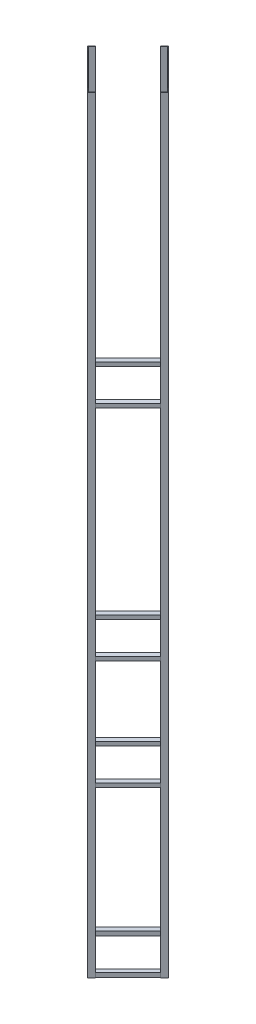
from build123d import *

# Parameters (mm, degrees)
BOSS_EXTRUDE6_DEPTH   = 1778
BOSS_EXTRUDE6_2_DEPTH = 1778
BOSS_EXTRUDE6_3_DEPTH = 1778
BOSS_EXTRUDE6_4_DEPTH = 1778
SKETCH11_W            = 11.1125
SKETCH11_H            = 9.525
BOSS_EXTRUDE11_DEPTH  = 129.12986
SKETCH13_W            = 11.1125
SKETCH13_H            = 9.525
BOSS_EXTRUDE13_DEPTH  = 118.01736
SKETCH14_W            = 11.1125
SKETCH14_H            = 9.525
BOSS_EXTRUDE14_DEPTH  = 119.60486
SKETCH15_W            = 11.1125
SKETCH15_H            = 9.525
BOSS_EXTRUDE15_DEPTH  = 106.90486
LPATTERN1_COUNT       = 2
LPATTERN1_PITCH       = 381
LPATTERN2_COUNT       = 2
LPATTERN2_PITCH       = 635
LPATTERN3_COUNT       = 2
LPATTERN3_PITCH       = 1143
SKETCH16_W            = 12.7
SKETCH16_H            = 12.7
BOSS_EXTRUDE16_DEPTH  = 0.0254
SKETCH17_W            = 12.7
SKETCH17_H            = 12.7
BOSS_EXTRUDE17_DEPTH  = 0.0254
SKETCH18_W            = 1.5875
SKETCH18_H            = 12.7
BOSS_EXTRUDE18_DEPTH  = 0.0254
SKETCH19_W            = 1.5875
SKETCH19_H            = 12.7
BOSS_EXTRUDE19_DEPTH  = 0.0254


with BuildPart() as part:
    # Sketch2 → Boss-Extrude6 (new body)
    with BuildSketch(Plane(origin=(0, 0, 0), x_dir=(1, 0, 0), z_dir=(0, 1, 0))):
        Polygon((0, 93.553663338), (-8.980256121, 84.573407217), (-7.857724106, 83.450875201), (0, 91.308599307), (7.857724106, 83.450875201), (8.980256121, 84.573407217), align=None)
    extrude(amount=BOSS_EXTRUDE6_DEPTH)



with BuildPart() as body_2:
    # Sketch2 → Boss-Extrude6 2 (new body)
    with BuildSketch(Plane(origin=(0, 0, 0), x_dir=(1, 0, 0), z_dir=(0, 1, 0))):
        Polygon((93.553663338, 0), (84.573407217, 8.980256121), (83.450875201, 7.857724106), (91.308599307, 0), (83.450875201, -7.857724106), (84.573407217, -8.980256121), align=None)
    extrude(amount=BOSS_EXTRUDE6_2_DEPTH)



with BuildPart() as body_3:
    # Sketch2 → Boss-Extrude6 3 (new body)
    with BuildSketch(Plane(origin=(0, 0, 0), x_dir=(1, 0, 0), z_dir=(0, 1, 0))):
        Polygon((0, -93.553663338), (8.980256121, -84.573407217), (7.857724106, -83.450875201), (0, -91.308599307), (-7.857724106, -83.450875201), (-8.980256121, -84.573407217), align=None)
    extrude(amount=BOSS_EXTRUDE6_3_DEPTH)



with BuildPart() as body_4:
    # Sketch2 → Boss-Extrude6 4 (new body)
    with BuildSketch(Plane(origin=(0, 0, 0), x_dir=(1, 0, 0), z_dir=(0, 1, 0))):
        Polygon((-93.553663338, 0), (-84.573407217, -8.980256121), (-83.450875201, -7.857724106), (-91.308599307, 0), (-83.450875201, 7.857724106), (-84.573407217, 8.980256121), align=None)
    extrude(amount=BOSS_EXTRUDE6_4_DEPTH)


with BuildPart() as body_3_1:
    add(body_3.part)

    add(body_4.part)  # Boss-Extrude11 merges body 4
    # Sketch11 → Boss-Extrude11 (add)
    with BuildSketch(Plane(origin=(-45.654299654, 0, -45.654299654), x_dir=(0.707106781, 0, -0.707106781), z_dir=(0.707106781, 0, 0.707106781))):
        with Locations((-59.008679751, 4.7625)):
            Rectangle(SKETCH11_W, SKETCH11_H)
    boss_extrude11 = extrude(amount=BOSS_EXTRUDE11_DEPTH)


with BuildPart() as body_2_1:
    add(body_2.part)

    add(body_3_1.part)  # Boss-Extrude13 merges body 3
    # Sketch13 → Boss-Extrude13 (add)
    with BuildSketch(Plane(origin=(-37.796575548, 0, 37.796575548), x_dir=(-0.707106781, 0, -0.707106781), z_dir=(0.707106781, 0, -0.707106781))):
        with Locations((-59.008679751, 4.7625)):
            Rectangle(SKETCH13_W, SKETCH13_H)
    boss_extrude13 = extrude(amount=BOSS_EXTRUDE13_DEPTH)


with BuildPart() as part_1:
    add(part.part)

    add(body_2_1.part)  # Boss-Extrude14 merges body 2
    # Sketch14 → Boss-Extrude14 (add)
    with BuildSketch(Plane(origin=(37.796575548, 0, 37.796575548), x_dir=(-0.707106781, 0, 0.707106781), z_dir=(-0.707106781, 0, -0.707106781))):
        with Locations((-59.008679751, 4.7625)):
            Rectangle(SKETCH14_W, SKETCH14_H)
    boss_extrude14 = extrude(amount=BOSS_EXTRUDE14_DEPTH)

    # Sketch15 → Boss-Extrude15 (add)
    with BuildSketch(Plane(origin=(37.796575548, 0, -37.796575548), x_dir=(0.707106781, 0, 0.707106781), z_dir=(-0.707106781, 0, 0.707106781))):
        with Locations((-59.008679751, 4.7625)):
            Rectangle(SKETCH15_W, SKETCH15_H)
    boss_extrude15 = extrude(amount=BOSS_EXTRUDE15_DEPTH)

    # LPattern1: Boss-Extrude11, Boss-Extrude13, Boss-Extrude14, Boss-Extrude15 ×2
    with Locations(*[(0, i * LPATTERN1_PITCH, 0) for i in range(1, LPATTERN1_COUNT)]):
        add(boss_extrude11)
        add(boss_extrude13)
        add(boss_extrude14)
        add(boss_extrude15)

    # LPattern2: Boss-Extrude11, Boss-Extrude13, Boss-Extrude14, Boss-Extrude15 ×2
    with Locations(*[(0, i * LPATTERN2_PITCH, 0) for i in range(1, LPATTERN2_COUNT)]):
        add(boss_extrude11)
        add(boss_extrude13)
        add(boss_extrude14)
        add(boss_extrude15)

    # LPattern3: Boss-Extrude11, Boss-Extrude13, Boss-Extrude14, Boss-Extrude15 ×2
    with Locations(*[(0, i * LPATTERN3_PITCH, 0) for i in range(1, LPATTERN3_COUNT)]):
        add(boss_extrude11)
        add(boss_extrude13)
        add(boss_extrude14)
        add(boss_extrude15)

    # Sketch16 → Boss-Extrude16 (add)
    with BuildSketch(Plane(origin=(-46.776831669, 0, 46.776831669), x_dir=(0.707106781, 0, 0.707106781), z_dir=(-0.707106781, 0, 0.707106781))):
        with Locations((-59.802429751, 1771.65)):
            Rectangle(SKETCH16_W, SKETCH16_H)
    extrude(amount=BOSS_EXTRUDE16_DEPTH)

    # Sketch17 → Boss-Extrude17 (add)
    with BuildSketch(Plane(origin=(-46.776831669, 0, 46.776831669), x_dir=(0.707106781, 0, 0.707106781), z_dir=(-0.707106781, 0, 0.707106781))):
        with Locations((59.802429751, 1771.65)):
            Rectangle(SKETCH17_W, SKETCH17_H)
    extrude(amount=BOSS_EXTRUDE17_DEPTH)

    # Sketch18 → Boss-Extrude18 (add)
    with BuildSketch(Plane(origin=(37.796575548, 0, -37.796575548), x_dir=(0.707106781, 0, 0.707106781), z_dir=(-0.707106781, 0, 0.707106781))):
        with Locations((-65.358679751, 1771.65)):
            Rectangle(SKETCH18_W, SKETCH18_H)
    extrude(amount=BOSS_EXTRUDE18_DEPTH)

    # Sketch19 → Boss-Extrude19 (add)
    with BuildSketch(Plane(origin=(37.796575548, 0, -37.796575548), x_dir=(0.707106781, 0, 0.707106781), z_dir=(-0.707106781, 0, 0.707106781))):
        with Locations((65.358679751, 1771.65)):
            Rectangle(SKETCH19_W, SKETCH19_H)
    extrude(amount=BOSS_EXTRUDE19_DEPTH)


solid = part_1.part
